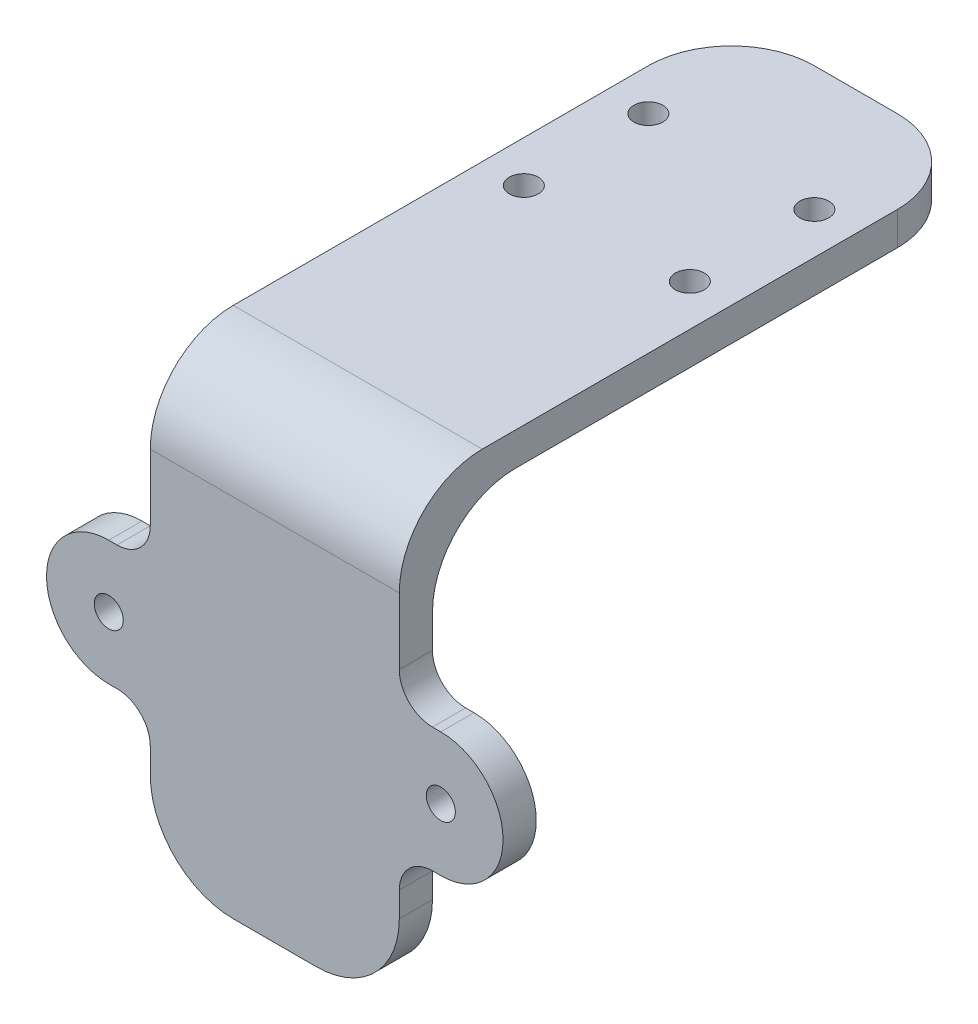
from build123d import *

# Parameters (mm, degrees)
SKETCH1_W            = 30
SKETCH1_H            = 70
BOSS_EXTRUDE1_DEPTH  = 2
SKETCH2_W            = 30
SKETCH2_H            = 4
BOSS_EXTRUDE2_DEPTH  = 50
SKETCH3_R            = 1.75
BOSS_EXTRUDE3_DEPTH  = 4
SKETCH4_R            = 1.75
CUT_EXTRUDE1_DEPTH   = 4
LPATTERN1_COUNT      = 2
LPATTERN1_PITCH      = 15
LPATTERN1_COUNT_DIR2 = 2
LPATTERN1_PITCH_DIR2 = 20
FILLET1_R            = 10
FILLET2_R            = 4


with BuildPart() as part:
    # Sketch1 → Boss-Extrude1 (new body, symmetric)
    with BuildSketch(Plane(origin=(0, 0, 0), x_dir=(1, 0, 0), z_dir=(0, 1, 0))):
        Rectangle(SKETCH1_W, SKETCH1_H)
    extrude(amount=BOSS_EXTRUDE1_DEPTH, both=True)

    # Sketch2 → Boss-Extrude2 (add)
    with BuildSketch(Plane.XZ.offset(2)):
        with Locations((0, 33)):
            Rectangle(SKETCH2_W, SKETCH2_H)
    extrude(amount=BOSS_EXTRUDE2_DEPTH)

    # Sketch3 → Boss-Extrude3 (add)
    with BuildSketch(Plane.XY.offset(35)):
        with BuildLine():
            Line((20, -20), (-20, -20))
            ThreePointArc((-20, -20), (-27.5, -27.5), (-20, -35))
            Line((-20, -35), (20, -35))
            ThreePointArc((20, -35), (27.5, -27.5), (20, -20))
        make_face()
        with Locations((-20, -27.5)):
            Circle(SKETCH3_R, mode=Mode.SUBTRACT)
        with Locations((20, -27.5)):
            Circle(SKETCH3_R, mode=Mode.SUBTRACT)
    extrude(amount=-BOSS_EXTRUDE3_DEPTH)

    # Sketch4 → Cut-Extrude1 (cut)
    with BuildSketch(Plane(origin=(0, 2, 0), x_dir=(1, 0, 0), z_dir=(0, 1, 0))):
        with Locations((-10, 20)):
            Circle(SKETCH4_R)
    cut_extrude1 = extrude(amount=-CUT_EXTRUDE1_DEPTH, mode=Mode.SUBTRACT)

    # LPattern1: Cut-Extrude1 2 × 2
    with Locations(*[(j * LPATTERN1_PITCH_DIR2, 0, i * LPATTERN1_PITCH) for i in range(LPATTERN1_COUNT) for j in range(LPATTERN1_COUNT_DIR2) if (i, j) != (0, 0)]):
        add(cut_extrude1, mode=Mode.SUBTRACT)

    # Fillet1
    fillet1_edges = [part.edges().sort_by_distance(p)[0] for p in [
        (0, -2, 31),
        (15, -52, 33),
        (0, 2, 35),
        (-15, -52, 33),
        (-15, 0, -35),
        (15, 0, -35),
    ]]
    fillet(fillet1_edges, radius=FILLET1_R)

    # Fillet2
    fillet2_edges = [part.edges().sort_by_distance(p)[0] for p in [
        (15, -35, 33),
        (-15, -35, 33),
        (15, -20, 33),
        (-15, -20, 33),
    ]]
    fillet(fillet2_edges, radius=FILLET2_R)


solid = part.part
